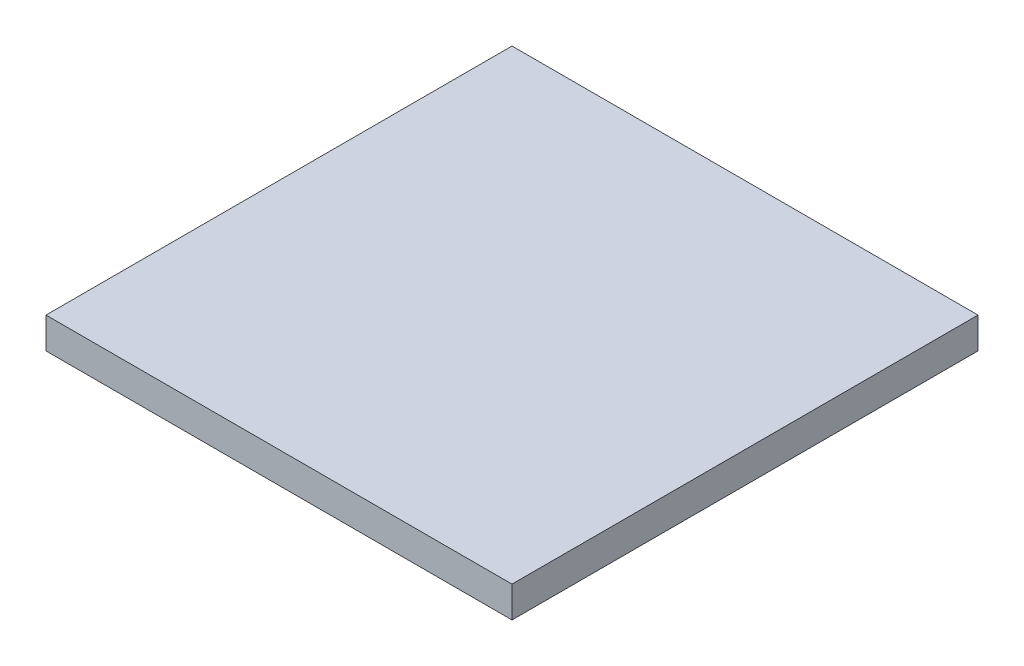
from build123d import *

# Parameters (mm, degrees)
SKETCH1_W           = 381
SKETCH1_H           = 25.4
BOSS_EXTRUDE1_DEPTH = 381


with BuildPart() as part:
    # Sketch1 → Boss-Extrude1 (new body)
    with BuildSketch(Plane.XY):
        with Locations((190.5, 12.7)):
            Rectangle(SKETCH1_W, SKETCH1_H)
    extrude(amount=BOSS_EXTRUDE1_DEPTH)


solid = part.part
